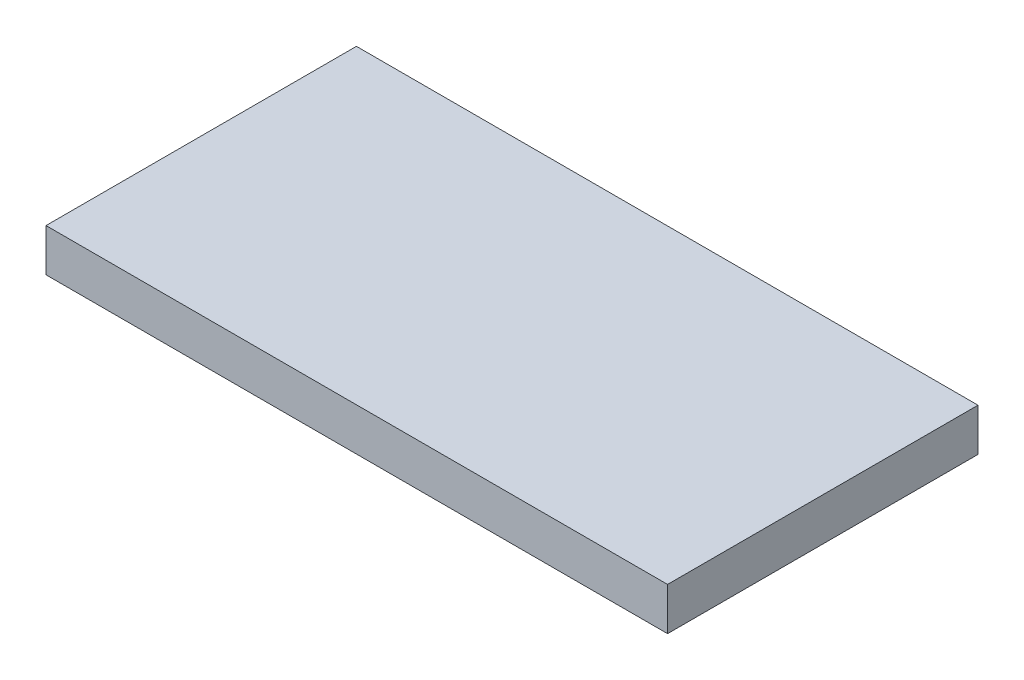
from build123d import *

# Parameters (mm, degrees)
SKETCH1_W           = 192.0875
SKETCH1_H           = 95.9358
BOSS_EXTRUDE1_DEPTH = 13.1826
SKETCH2_W           = 166.1795
SKETCH2_H           = 70.0278
CUT_EXTRUDE1_DEPTH  = 7.874
SKETCH3_R           = 1.27
CUT_EXTRUDE2_DEPTH  = 7.874
SKETCH4_W           = 15.7988
SKETCH4_H           = 8.2804
BOSS_EXTRUDE2_DEPTH = 9.8298
SKETCH5_W           = 8.89
SKETCH5_H           = 27.94
BOSS_EXTRUDE3_DEPTH = 7.874
SKETCH6_R           = 1.0668
BOSS_EXTRUDE4_DEPTH = 3.683
FILLET1_R           = 5.08
FILLET2_R           = 0.635


with BuildPart() as part:
    # Sketch1 → Boss-Extrude1 (new body)
    with BuildSketch(Plane(origin=(0, 0, 0), x_dir=(1, 0, 0), z_dir=(0, 1, 0))):
        with Locations((96.04375, 47.9679)):
            Rectangle(SKETCH1_W, SKETCH1_H)
    extrude(amount=BOSS_EXTRUDE1_DEPTH)

    # Sketch2 → Cut-Extrude1 (cut)
    with BuildSketch(Plane.XZ):
        with Locations((96.04375, -47.9679)):
            Rectangle(SKETCH2_W, SKETCH2_H)
    extrude(amount=-CUT_EXTRUDE1_DEPTH, mode=Mode.SUBTRACT)

    # Sketch3 → Cut-Extrude2 (cut)
    with BuildSketch(Plane.XZ):
        with Locations((12.7, -85.7758)):
            Circle(SKETCH3_R)
        with Locations((12.7, -10.16)):
            Circle(SKETCH3_R)
        with Locations((179.3875, -85.7758)):
            Circle(SKETCH3_R)
        with Locations((179.3875, -10.16)):
            Circle(SKETCH3_R)
    extrude(amount=-CUT_EXTRUDE2_DEPTH, mode=Mode.SUBTRACT)

    # Sketch4 → Boss-Extrude2 (add)
    with BuildSketch(Plane(origin=(0, 7.874, 0), x_dir=(-1, 0, 0), z_dir=(0, -1, 0))):
        with Locations((-74.1934, 49.8094)):
            Rectangle(SKETCH4_W, SKETCH4_H)
    extrude(amount=BOSS_EXTRUDE2_DEPTH)

    # Sketch5 → Boss-Extrude3 (add)
    with BuildSketch(Plane(origin=(0, 7.874, 0), x_dir=(-1, 0, 0), z_dir=(0, -1, 0))):
        with Locations((-21.2598, 48.387)):
            Rectangle(SKETCH5_W, SKETCH5_H)
        with Locations((-170.8277, 48.387)):
            Rectangle(SKETCH5_W, SKETCH5_H)
    extrude(amount=BOSS_EXTRUDE3_DEPTH)

    # Sketch6 → Boss-Extrude4 (add)
    with BuildSketch(Plane(origin=(0, 0, 0), x_dir=(-1, 0, 0), z_dir=(0, -1, 0))):
        with Locations((-8.2804, 17.8562)):
            Circle(SKETCH6_R)
        with Locations((-183.8071, 78.0796)):
            Circle(SKETCH6_R)
    extrude(amount=BOSS_EXTRUDE4_DEPTH)

    # Fillet1
    fillet1_edges = [part.edges().sort_by_distance(p)[0] for p in [
        (12.954, 3.937, -82.9818),
        (12.954, 3.937, -12.954),
        (179.1335, 3.937, -12.954),
        (179.1335, 3.937, -82.9818),
    ]]
    fillet(fillet1_edges, radius=FILLET1_R)

    # Fillet2
    fillet2_edges = [part.edges().sort_by_distance(p)[0] for p in [
        (9.3472, -3.683, -17.8562),
        (184.8739, -3.683, -78.0796),
    ]]
    fillet(fillet2_edges, radius=FILLET2_R)


solid = part.part
